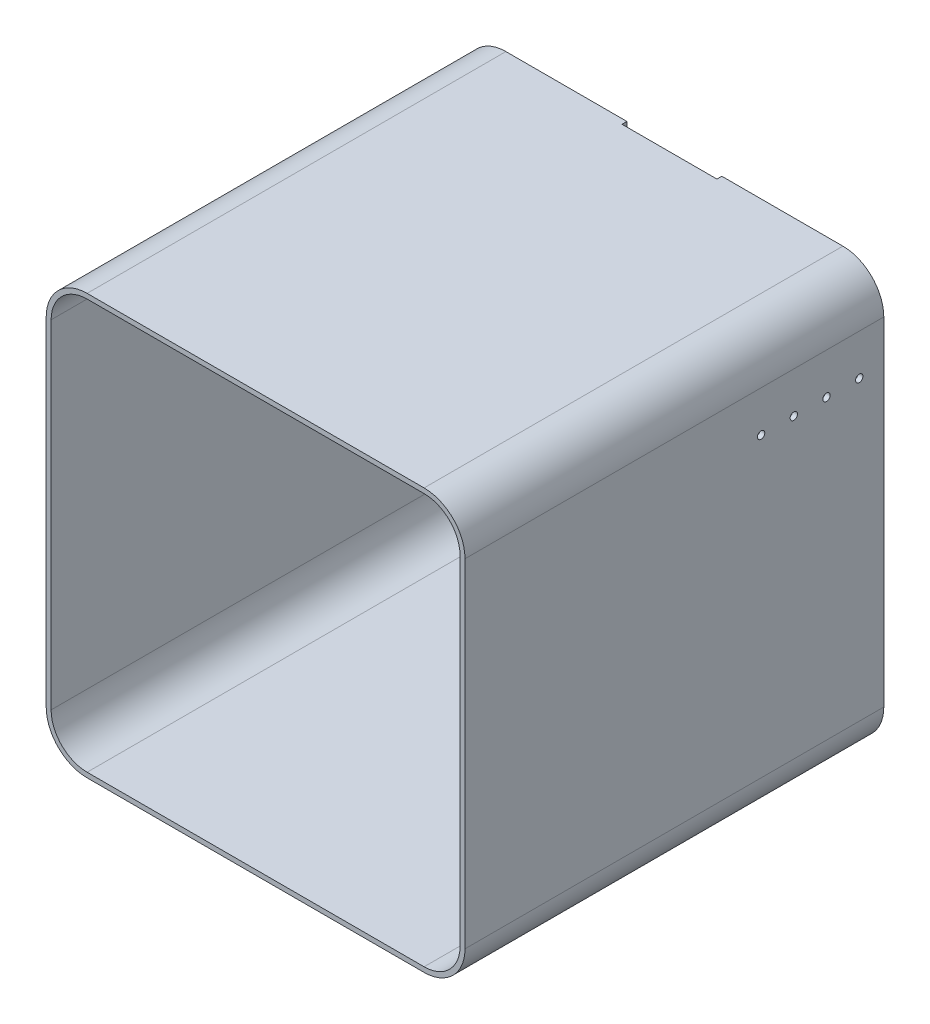
from build123d import *

# Parameters (mm, degrees)
EXTRUDE_THIN1_DEPTH = 512
SKETCH3_R           = 4.5
CUT_EXTRUDE1_DEPTH  = 10
LPATTERN1_COUNT     = 4
LPATTERN1_PITCH     = 40
SKETCH4_W           = 116
SKETCH4_H           = 6
CUT_EXTRUDE2_DEPTH  = 6


with BuildPart() as part:
    # Sketch1 → Extrude-Thin1 (new body)
    with BuildSketch(Plane.XY):
        with BuildLine():
            Line((44, -6), (456, -6))
            ThreePointArc((456, -6), (491.355339059, 8.644660941), (506, 44))
            Line((506, 44), (506, 457))
            ThreePointArc((506, 457), (491.355339059, 492.355339059), (456, 507))
            Line((456, 507), (44, 507))
            ThreePointArc((44, 507), (8.644660941, 492.355339059), (-6, 457))
            Line((-6, 457), (-6, 44))
            ThreePointArc((-6, 44), (8.644660941, 8.644660941), (44, -6))
        make_face()
        with BuildLine():
            Line((44, 0), (456, 0))
            ThreePointArc((456, 0), (487.112698372, 12.887301628), (500, 44))
            Line((500, 44), (500, 457))
            ThreePointArc((500, 457), (487.112698372, 488.112698372), (456, 501))
            Line((456, 501), (44, 501))
            ThreePointArc((44, 501), (12.887301628, 488.112698372), (0, 457))
            Line((0, 457), (0, 44))
            ThreePointArc((0, 44), (12.887301628, 12.887301628), (44, 0))
        make_face(mode=Mode.SUBTRACT)
    extrude(amount=-EXTRUDE_THIN1_DEPTH)

    # Sketch3 → Cut-Extrude1 (cut)
    with BuildSketch(Plane(origin=(506, 0, 0), x_dir=(0, 0, -1), z_dir=(1, 0, 0))):
        with Locations((482, 407)):
            Circle(SKETCH3_R)
    cut_extrude1 = extrude(amount=-CUT_EXTRUDE1_DEPTH, mode=Mode.SUBTRACT)

    # LPattern1: Cut-Extrude1 ×4
    with Locations(*[(0, 0, i * LPATTERN1_PITCH) for i in range(1, LPATTERN1_COUNT)]):
        add(cut_extrude1, mode=Mode.SUBTRACT)

    # Sketch4 → Cut-Extrude2 (cut)
    with BuildSketch(Plane(origin=(0, 0, -512), x_dir=(-1, 0, 0), z_dir=(0, 0, -1))):
        with Locations((-250, 504)):
            Rectangle(SKETCH4_W, SKETCH4_H)
    extrude(amount=-CUT_EXTRUDE2_DEPTH, mode=Mode.SUBTRACT)


solid = part.part
